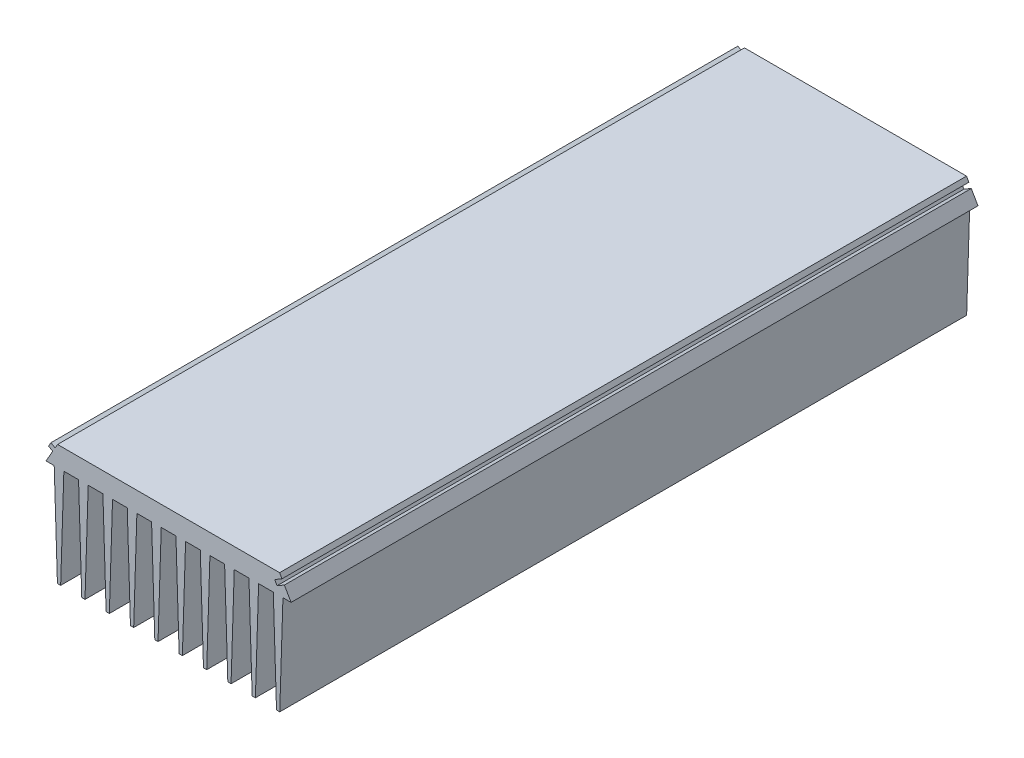
from build123d import *

# Parameters (mm, degrees)
RESSALTO_EXTRUS_O1_DEPTH   = 285
CORTE_EXTRUS_O1_DEPTH      = 1
CORTE_EXTRUS_O1_DEPTH_BACK = 286


with BuildPart() as part:
    # Esboço1 → Ressalto-extrusão1 (new body)
    with BuildSketch(Plane.XY):
        Polygon((0.129363371, 0.000429576), (0.129363371, 50.000429576), (115.229363371, 50.000429576), (115.229363371, 0.000429576), (112.558897843, 0.0275034), (111.229363371, 41.700429576), (105.129363371, 41.700429576), (103.799966135, 0.000429576), (102.459761608, 0.000429576), (101.129363371, 41.700429576), (95.029363371, 41.700429576), (93.699966135, 0.000429576), (92.359761608, 0.000429576), (91.029363371, 41.700429576), (84.929363371, 41.700429576), (83.599966135, 0.000429576), (82.259761608, 0.000429576), (80.929363371, 41.700429576), (74.829363371, 41.700429576), (73.499966135, 0.000429576), (72.159761608, 0.000429576), (70.829363371, 41.700429576), (64.729363371, 41.700429576), (63.399966135, 0.000429576), (62.059761608, 0.000429576), (60.729363371, 41.700429576), (54.629363371, 41.700429576), (53.299966135, 0.000429576), (51.959761608, 0.000429576), (50.629363371, 41.700429576), (44.529363371, 41.700429576), (43.199966135, 0.000429576), (41.859761608, 0.000429576), (40.529363371, 41.700429576), (34.429363371, 41.700429576), (33.099966135, 0.000429576), (31.759761608, 0.000429576), (30.429363371, 41.700429576), (24.329363371, 41.700429576), (22.999966135, 0.000429576), (21.659761608, 0.000429576), (20.329363371, 41.700429576), (14.229363371, 41.700429576), (12.899966135, 0.000429576), (11.559761608, 0.000429576), (10.229363371, 41.700429576), (4.129363371, 41.700429576), (2.799966135, 0.000429576), align=None)
    extrude(amount=RESSALTO_EXTRUS_O1_DEPTH)

    # Esboço2 → Corte-extrusão1 (cut, two sides)
    with BuildSketch(Plane(origin=(0, 0, 0), x_dir=(-1, 0, 0), z_dir=(0, 0, -1))) as corte_extrus_o1_sk:
        Polygon((-104.72087071, 48.268772175), (-101.689781797, 46.518772175), (-102.689781797, 44.786721368), (-105.72087071, 46.536721368), (-108.513105078, 41.700429576), (-108.513105078, 0.000429576), (-115.229363371, 0.000429576), (-115.229363371, 50.000429576), (-103.74577832, 50.000429576), align=None)
        Polygon((-10.613175555, 48.268772175), (-8.881124748, 49.268772175), (-7.881124748, 47.536721368), (-9.613175555, 46.536721368), (-6.820941187, 41.700429576), (-6.820941187, 0), (0, 0), (-0.129363371, 50.000429576), (-11.612948422, 50.000429576), align=None)
    extrude(amount=CORTE_EXTRUS_O1_DEPTH, mode=Mode.SUBTRACT)
    extrude(corte_extrus_o1_sk.sketch, amount=-CORTE_EXTRUS_O1_DEPTH_BACK, mode=Mode.SUBTRACT)


solid = part.part
